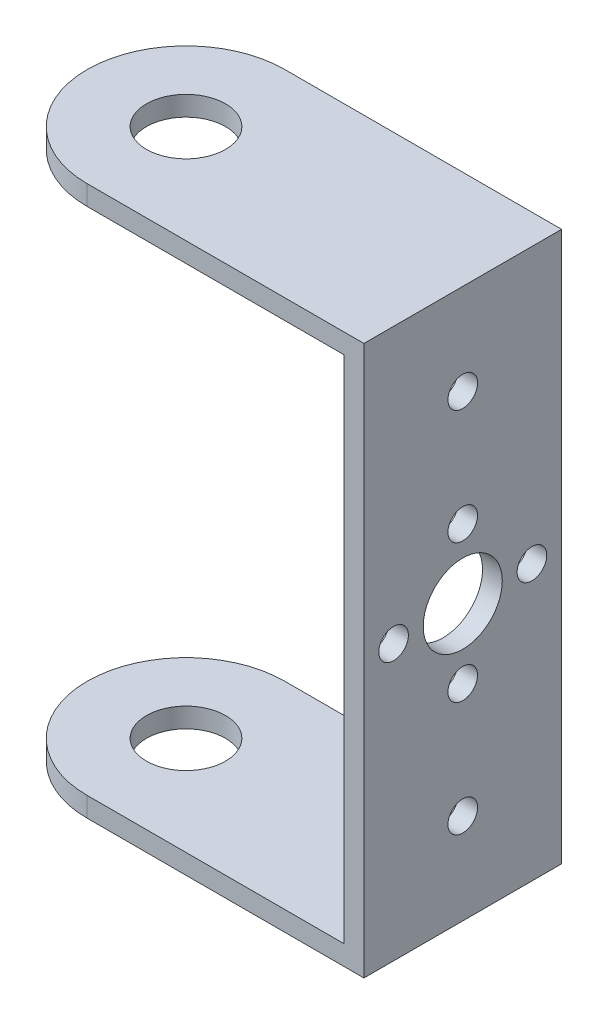
from build123d import *

# Parameters (mm, degrees)
SALIENTE_EXTRUIR1_DEPTH = 20
SALIENTE_EXTRUIR2_DEPTH = 2
SALIENTE_EXTRUIR3_DEPTH = 2
CROQUIS4_R              = 4
CORTAR_EXTRUIR1_DEPTH   = 2
CROQUIS5_R              = 4
CORTAR_EXTRUIR2_DEPTH   = 2
CORTAR_EXTRUIR3_DEPTH   = 2
CROQUIS7_R              = 1.5
CORTAR_EXTRUIR4_DEPTH   = 2
CROQUIS8_R              = 1.5
CORTAR_EXTRUIR5_DEPTH   = 2


with BuildPart() as part:
    # Croquis1 → Saliente-Extruir1 (new body)
    with BuildSketch(Plane.XY):
        Polygon((-12, 25.8), (12, 25.8), (12, -25.8), (-12, -25.8), (-14, -25.8), (-14, -27.8), (14, -27.8), (14, 27.8), (-14, 27.8), (-14, 25.8), align=None)
    extrude(amount=SALIENTE_EXTRUIR1_DEPTH)

    # Croquis2 → Saliente-Extruir2 (add)
    with BuildSketch(Plane(origin=(0, 27.8, 0), x_dir=(1, 0, 0), z_dir=(0, 1, 0))):
        with BuildLine():
            Line((-14, -20), (-14, 0))
            ThreePointArc((-14, 0), (-24, -10), (-14, -20))
        make_face()
    extrude(amount=-SALIENTE_EXTRUIR2_DEPTH)

    # Croquis3 → Saliente-Extruir3 (add)
    with BuildSketch(Plane(origin=(0, -25.8, 0), x_dir=(1, 0, 0), z_dir=(0, 1, 0))):
        with BuildLine():
            Line((-14, -20), (-14, 0))
            ThreePointArc((-14, 0), (-24, -10), (-14, -20))
        make_face()
    extrude(amount=-SALIENTE_EXTRUIR3_DEPTH)

    # Croquis4 → Cortar-Extruir1 (cut)
    with BuildSketch(Plane(origin=(0, 27.8, 0), x_dir=(1, 0, 0), z_dir=(0, 1, 0))):
        with Locations((-14, -10)):
            Circle(CROQUIS4_R)
    extrude(amount=-CORTAR_EXTRUIR1_DEPTH, mode=Mode.SUBTRACT)

    # Croquis5 → Cortar-Extruir2 (cut)
    with BuildSketch(Plane(origin=(0, -25.8, 0), x_dir=(1, 0, 0), z_dir=(0, 1, 0))):
        with Locations((-14, -10)):
            Circle(CROQUIS5_R)
    extrude(amount=-CORTAR_EXTRUIR2_DEPTH, mode=Mode.SUBTRACT)

    # Croquis6 → Cortar-Extruir3 (cut)
    with BuildSketch(Plane(origin=(14, 0, 0), x_dir=(0, 0, -1), z_dir=(1, 0, 0))):
        with BuildLine():
            ThreePointArc((-6, 0), (-7.699530032, 3.272283289), (-11.353918963, 3.763894717))
            Line((-11.353918963, 3.763894717), (-8.646081037, -3.763894717))
            ThreePointArc((-8.646081037, -3.763894717), (-6.727716711, -2.300469968), (-6, 0))
        make_face()
        with BuildLine():
            Line((-8.646081037, -3.763894717), (-11.353918963, 3.763894717))
            ThreePointArc((-11.353918963, 3.763894717), (-13.763894717, -1.353918963), (-8.646081037, -3.763894717))
        make_face()
    extrude(amount=-CORTAR_EXTRUIR3_DEPTH, mode=Mode.SUBTRACT)

    # Croquis7 → Cortar-Extruir4 (cut)
    with BuildSketch(Plane(origin=(14, 0, 0), x_dir=(0, 0, -1), z_dir=(1, 0, 0))):
        with Locations((-10, 7)):
            Circle(CROQUIS7_R)
        with Locations((-3, 0)):
            Circle(CROQUIS7_R)
        with Locations((-10, -7)):
            Circle(CROQUIS7_R)
        with Locations((-17, 0)):
            Circle(CROQUIS7_R)
    extrude(amount=-CORTAR_EXTRUIR4_DEPTH, mode=Mode.SUBTRACT)

    # Croquis8 → Cortar-Extruir5 (cut)
    with BuildSketch(Plane(origin=(14, 0, 0), x_dir=(0, 0, -1), z_dir=(1, 0, 0))):
        with Locations((-10, 18.6)):
            Circle(CROQUIS8_R)
        with Locations((-10, -18.6)):
            Circle(CROQUIS8_R)
    extrude(amount=-CORTAR_EXTRUIR5_DEPTH, mode=Mode.SUBTRACT)


solid = part.part
